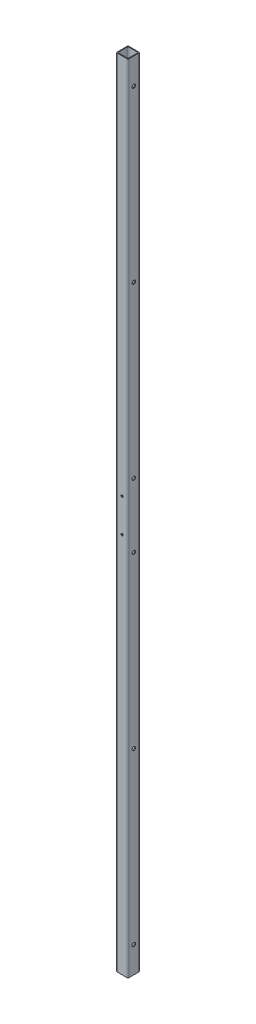
from build123d import *

# Parameters (mm, degrees)
SKETCH1_W                  = 19.304
SKETCH1_H                  = 19.304
SKETCH1_W_2                = 16.764
SKETCH1_H_2                = 16.764
BOSS_EXTRUDE1_DEPTH        = 1309.624
FILLET1_R                  = 1.27
F_1_0_228_DIAMETER_HOLE1_D = 5.7912
F_8_32_TAPPED_HOLE1_D      = 3.4544


with BuildPart() as part:
    # Sketch1 → Boss-Extrude1 (new body)
    with BuildSketch(Plane(origin=(0, 0, 0), x_dir=(1, 0, 0), z_dir=(0, 1, 0))):
        Rectangle(SKETCH1_W, SKETCH1_H)
        Rectangle(SKETCH1_W_2, SKETCH1_H_2, mode=Mode.SUBTRACT)
    extrude(amount=BOSS_EXTRUDE1_DEPTH)

    # Fillet1
    fillet1_edges = [part.edges().sort_by_distance(p)[0] for p in [
        (-8.382, 654.812, 8.382),
        (8.382, 654.812, 8.382),
        (8.382, 654.812, -8.382),
        (-8.382, 654.812, -8.382),
        (9.652, 654.812, 9.652),
        (-9.652, 654.812, 9.652),
        (-9.652, 654.812, -9.652),
        (9.652, 654.812, -9.652),
    ]]
    fillet(fillet1_edges, radius=FILLET1_R)

    # #1 (0.228) Diameter Hole1 (through all)
    with Locations(Plane(origin=(9.652, 0, 0), x_dir=(0, 0, -1), z_dir=(1, 0, 0))):
        with Locations((0, 601.98), (0, 1266.444), (0, 987.044), (0, 707.644), (0, 43.18), (0, 322.58)):
            Hole(F_1_0_228_DIAMETER_HOLE1_D / 2)

    # #8-32 Tapped Hole1 (through all)
    with Locations(Plane(origin=(0, 0, -9.652), x_dir=(-1, 0, 0), z_dir=(0, 0, -1))):
        with Locations((0, 627.38), (0, 682.244)):
            Hole(F_8_32_TAPPED_HOLE1_D / 2)


solid = part.part
